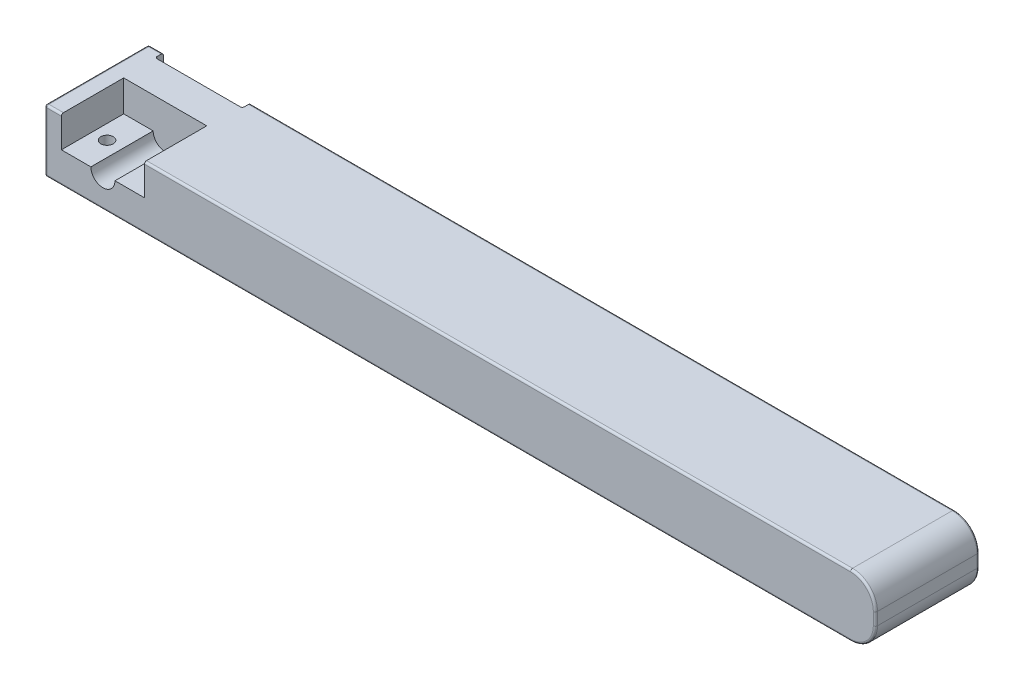
from build123d import *

# Parameters (mm, degrees)
IZIM1_W                     = 200
IZIM1_H                     = 15
Y_KSEKLIK_EKSTR_ZYON1_DEPTH = 25
RADYUS1_R                   = 6
IZIM3_R                     = 2.9
KES_EKSTR_ZYON2_DEPTH       = 1
KES_EKSTR_ZYON2_DEPTH_BACK  = 15
KES_EKSTR_ZYON3_DEPTH       = 10
IZIM6_R                     = 1.45
KES_EKSTR_ZYON4_DEPTH       = 2
IZIM8_W                     = 20
IZIM8_H                     = 7.5
KES_EKSTR_ZYON6_DEPTH       = 15
IZIM9_R                     = 1.5
KES_EKSTR_ZYON7_DEPTH       = 15
RADYUS2_R                   = 0.5


with BuildPart() as part:
    # Çizim1 → Yükseklik-Ekstrüzyon1 (new body)
    with BuildSketch(Plane.XY):
        with Locations((-89.389671362, 2.546948357)):
            Rectangle(IZIM1_W, IZIM1_H)
    extrude(amount=Y_KSEKLIK_EKSTR_ZYON1_DEPTH)

    # Radyus1
    radyus1_edges = [part.edges().sort_by_distance(p)[0] for p in [
        (10.610328638, -4.953051643, 12.5),
        (10.610328638, 10.046948357, 12.5),
    ]]
    fillet(radyus1_edges, radius=RADYUS1_R)

    # Çizim3 → Kes-Ekstrüzyon2 (cut, two sides)
    with BuildSketch(Plane.XY.offset(25)) as kes_ekstr_zyon2_sk:
        with Locations((-175.389671362, 2.546948357)):
            Circle(IZIM3_R)
    extrude(amount=KES_EKSTR_ZYON2_DEPTH, mode=Mode.SUBTRACT)
    extrude(kes_ekstr_zyon2_sk.sketch, amount=-KES_EKSTR_ZYON2_DEPTH_BACK, mode=Mode.SUBTRACT)

    # Çizim4 → Kes-Ekstrüzyon3 (cut)
    with BuildSketch(Plane(origin=(0, 0, 0), x_dir=(-1, 0, 0), z_dir=(0, 0, -1))):
        with BuildLine():
            ThreePointArc((167.639671362, -0.633051643), (166.614366529, -3.108356476), (169.089671362, -2.083051643))
            Line((169.089671362, -2.083051643), (167.639671362, -2.083051643))
            Line((167.639671362, -2.083051643), (167.639671362, -0.633051643))
        make_face()
        with BuildLine():
            Line((167.639671362, -2.083051643), (169.089671362, -2.083051643))
            ThreePointArc((169.089671362, -2.083051643), (168.664976194, -1.05774681), (167.639671362, -0.633051643))
            Line((167.639671362, -0.633051643), (167.639671362, -2.083051643))
        make_face()
        with BuildLine():
            ThreePointArc((184.589671362, -2.083051643), (184.164976194, -1.05774681), (183.139671362, -0.633051643))
            Line((183.139671362, -0.633051643), (183.139671362, -2.083051643))
            Line((183.139671362, -2.083051643), (181.689671362, -2.083051643))
            ThreePointArc((181.689671362, -2.083051643), (183.139671362, -3.533051643), (184.589671362, -2.083051643))
        make_face()
        with BuildLine():
            Line((183.139671362, -2.083051643), (183.139671362, -0.633051643))
            ThreePointArc((183.139671362, -0.633051643), (182.114366529, -1.05774681), (181.689671362, -2.083051643))
            Line((181.689671362, -2.083051643), (183.139671362, -2.083051643))
        make_face()
    extrude(amount=-KES_EKSTR_ZYON3_DEPTH, mode=Mode.SUBTRACT)

    # Çizim6 → Kes-Ekstrüzyon4 (cut)
    with BuildSketch(Plane(origin=(0, 0, 0), x_dir=(-1, 0, 0), z_dir=(0, 0, -1))):
        Polygon((185.839671362, -4.953051643), (185.839671362, -2.083051643), (185.839671362, 10.046948357), (165.238795476, 10.046948357), (164.839671362, 10.046948357), (164.839671362, -4.953051643), align=None)
        with Locations((167.639671362, -2.083051643)):
            Circle(IZIM6_R, mode=Mode.SUBTRACT)
        with Locations((183.139671362, -2.083051643)):
            Circle(IZIM6_R, mode=Mode.SUBTRACT)
    extrude(amount=-KES_EKSTR_ZYON4_DEPTH, mode=Mode.SUBTRACT)

    # Çizim8 → Kes-Ekstrüzyon6 (cut)
    with BuildSketch(Plane.XY.offset(25)):
        with Locations((-175.389671362, 6.296948357)):
            Rectangle(IZIM8_W, IZIM8_H)
    extrude(amount=-KES_EKSTR_ZYON6_DEPTH, mode=Mode.SUBTRACT)

    # Çizim9 → Kes-Ekstrüzyon7 (cut)
    with BuildSketch(Plane(origin=(0, 2.546948357, 0), x_dir=(1, 0, 0), z_dir=(0, 1, 0))):
        with Locations((-168.889671362, -17.5)):
            Circle(IZIM9_R)
        with Locations((-181.889671362, -17.5)):
            Circle(IZIM9_R)
    extrude(amount=-KES_EKSTR_ZYON7_DEPTH, mode=Mode.SUBTRACT)

    # Radyus2
    radyus2_edges = [part.edges().sort_by_distance(p)[0] for p in [
        (-189.389671362, 2.546948357, 25),
        (-92.389671362, -4.953051643, 25),
        (10.610328638, 2.546948357, 0),
        (10.610328638, 2.546948357, 25),
        (-80.114671362, 10.046948357, 0),
        (8.852969326, 8.289589044, 0),
        (8.852969326, -3.19569233, 0),
        (-80.389671362, 10.046948357, 25),
        (8.852969326, 8.289589044, 25),
        (8.852969326, -3.19569233, 25),
        (-80.114671362, -4.953051643, 0),
        (-187.614671362, 10.046948357, 0),
        (-187.614671362, -4.953051643, 0),
        (-185.839671362, 2.546948357, 2),
        (-189.389671362, 2.546948357, 0),
        (-164.839671362, 2.546948357, 2),
        (-187.389671362, 10.046948357, 25),
        (-189.389671362, -4.953051643, 12.5),
        (-189.389671362, 10.046948357, 12.5),
    ]]
    fillet(radyus2_edges, radius=RADYUS2_R)


solid = part.part
